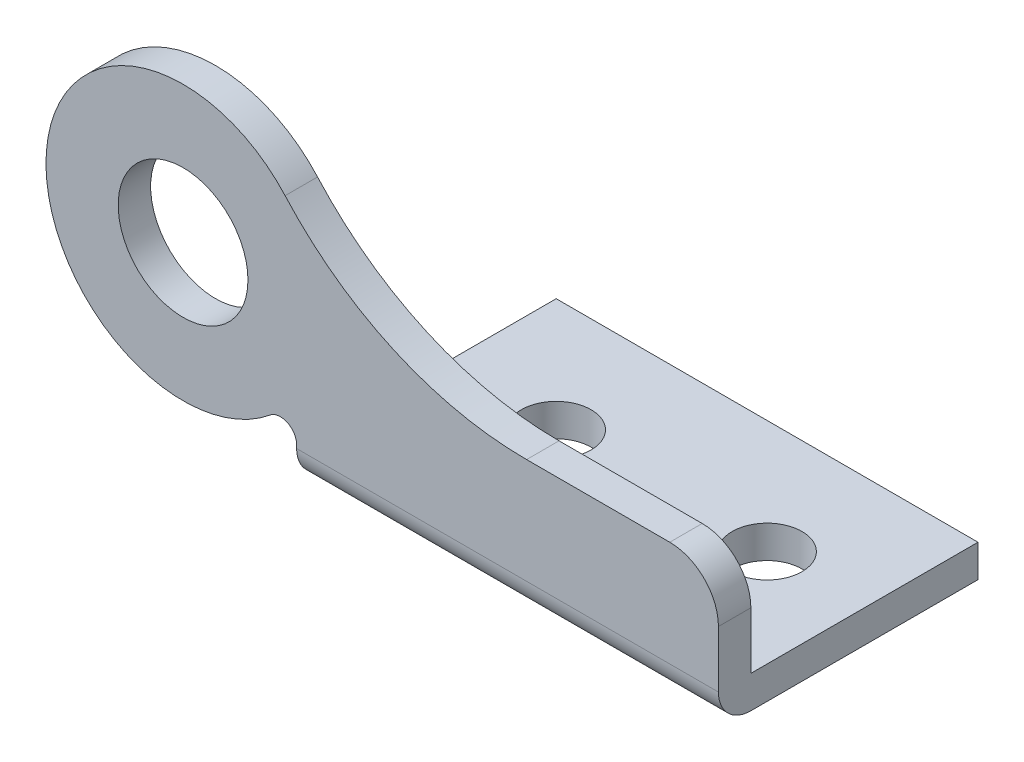
from build123d import *

# Parameters (mm, degrees)
EXTRUDE_1_DEPTH = 2
SKETCH_2_W      = 26
SKETCH_2_H      = 16
SKETCH_2_R      = 2.15
EXTRUDE_2_DEPTH = 2
FILLET_1_R      = 2


with BuildPart() as part:
    # 草图1 → 凸台-拉伸1 (new body)
    with BuildSketch(Plane.XY):
        with BuildLine():
            ThreePointArc((-5.068859013, 5.89218325), (1.666665094, 0.98511468), (9.817268595, -0.751050494))
            Line((9.817268595, -0.751050494), (18.641752073, -0.751050494))
            ThreePointArc((18.641752073, -0.751050494), (20.763072416, -1.62973015), (21.641752073, -3.751050494))
            Line((21.641752073, -3.751050494), (21.641752073, -7.251050494))
            Line((21.641752073, -7.251050494), (-4.358247927, -7.251050494))
            Line((-4.358247927, -7.251050494), (-4.358247927, -7.051906608))
            ThreePointArc((-4.358247927, -7.051906608), (-4.931001298, -6.147771487), (-5.993168562, -6.279329241))
            ThreePointArc((-5.993168562, -6.279329241), (-19.783987468, 0.888803553), (-5.068859013, 5.89218325))
        make_face()
        with BuildLine():
            ThreePointArc((-11.358247927, -3.751050494), (-7.358247927, 0.248949506), (-11.358247927, 4.248949506))
            ThreePointArc((-11.358247927, 4.248949506), (-15.358247927, 0.248949506), (-11.358247927, -3.751050494))
        make_face(mode=Mode.SUBTRACT)
        Polygon((19.641752073, -9.251050494), (-2.358247927, -9.251050494), (-4.358247927, -9.251050494), (-4.358247927, -7.251050494), (21.641752073, -7.251050494), (21.641752073, -9.251050494), align=None)
    extrude(amount=EXTRUDE_1_DEPTH)

    # 草图2 → 凸台-拉伸2 (add)
    with BuildSketch(Plane.XZ.offset(9.251050494)):
        with Locations((8.641752073, -6)):
            Rectangle(SKETCH_2_W, SKETCH_2_H)
        with Locations((2.641752073, -7)):
            Circle(SKETCH_2_R, mode=Mode.SUBTRACT)
        with BuildLine():
            ThreePointArc((13.82437189, -8.148751179), (15.043783592, -4.93482841), (17.791752073, -7))
            ThreePointArc((17.791752073, -7), (16.239720553, -9.06517159), (13.82437189, -8.148751179))
        make_face(mode=Mode.SUBTRACT)
    extrude(amount=-EXTRUDE_2_DEPTH)

    # 圆角1
    fillet_1_edges = [part.edges().sort_by_distance(p)[0] for p in [
        (8.641752073, -9.251050494, 2),
    ]]
    fillet(fillet_1_edges, radius=FILLET_1_R)


solid = part.part
